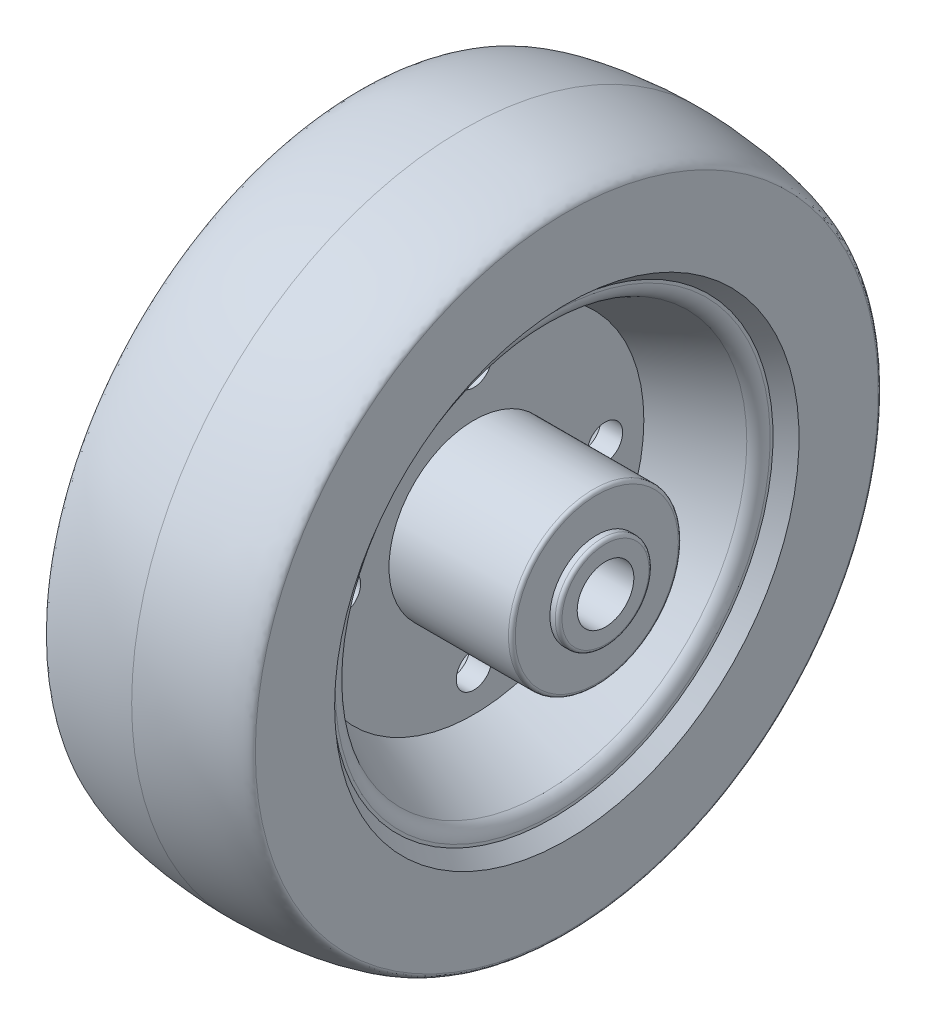
from build123d import *

# Parameters (mm, degrees)
SKETCH8_R            = 19.05
BOSS_EXTRUDE1_DEPTH  = 27.5463
SKETCH9_R            = 10.5156
BOSS_EXTRUDE2_DEPTH  = 1.9558
FILLET4_R            = 0.762
FILLET4_OF_MIRROR2_R = 0.762
SKETCH10_R           = 6.35
CUT_EXTRUDE5_DEPTH   = 64.9064
SKETCH11_R           = 3.96875
CUT_EXTRUDE6_DEPTH   = 35.4043


with BuildPart() as part:
    # Sketch5 → Revolve1 (revolve)
    with BuildSketch(Plane.XY):
        with BuildLine():
            Line((-23.2791, 0), (-23.2791, 69.85))
            add(Edge.make_bspline(
                [(-23.2791, 69.85), (-23.2791, 72.067965362), (-10.536247667, 74.295), (0, 74.295)],
                knots=[0, 0, 0, 0, 1, 1, 1, 1], degree=3))
            add(Edge.make_bspline(
                [(23.2791, 69.85), (23.2791, 72.067965362), (10.536247667, 74.295), (0, 74.295)],
                knots=[0, 0, 0, 0, 1, 1, 1, 1], degree=3))
            Line((23.2791, 69.85), (23.2791, 0))
            Line((23.2791, 0), (-23.2791, 0))
        make_face()
    revolve(axis=Axis((-23.2791, 0, 0), (1, 0, 0)))

    # Sketch7 → Cut-Revolve2 (revolve, cut)
    with BuildSketch(Plane(origin=(0, 0, 0), x_dir=(1, 0, 0), z_dir=(0, 1, 0))):
        with BuildLine():
            Line((2.4511, 0), (2.4511, 38.1))
            Line((2.4511, 38.1), (18.078907112, 45.553541634))
            ThreePointArc((18.078907112, 45.553541634), (19.555481427, 46.865602451), (20.1041, 48.763177998))
            Line((20.1041, 48.763177998), (20.1041, 49.412815204))
            Line((20.1041, 49.412815204), (23.2791, 52.07))
            Line((23.2791, 52.07), (23.2791, 0))
            Line((23.2791, 0), (2.4511, 0))
        make_face()
    cut_revolve2 = revolve(axis=Axis((-1000, 0, 0), (1, 0, 0)), mode=Mode.SUBTRACT)

    # Mirror1: Cut-Revolve2 across plane
    add(cut_revolve2.mirror(Plane(origin=(0, 0, 0), x_dir=(0, 0, 1), z_dir=(1, 0, 0))), mode=Mode.SUBTRACT)

    # Sketch8 → Boss-Extrude1 (add)
    with BuildSketch(Plane(origin=(2.4511, 0, 0), x_dir=(0, 0, -1), z_dir=(1, 0, 0))):
        Circle(SKETCH8_R)
    boss_extrude1 = extrude(amount=BOSS_EXTRUDE1_DEPTH)

    # Sketch9 → Boss-Extrude2 (add)
    with BuildSketch(Plane(origin=(29.9974, 0, 0), x_dir=(0, 0, -1), z_dir=(1, 0, 0))):
        Circle(SKETCH9_R)
    boss_extrude2 = extrude(amount=BOSS_EXTRUDE2_DEPTH)

    # Fillet4
    fillet4_edges = [part.edges().sort_by_distance(p)[0] for p in [
        (29.9974, 0, 19.05),
        (31.9532, 0, 10.5156),
    ]]
    fillet(fillet4_edges, radius=FILLET4_R)

    # Mirror2: Boss-Extrude1, Boss-Extrude2 across plane
    add(boss_extrude1.mirror(Plane(origin=(0, 0, 0), x_dir=(0, 0, 1), z_dir=(1, 0, 0))))
    add(boss_extrude2.mirror(Plane(origin=(0, 0, 0), x_dir=(0, 0, 1), z_dir=(1, 0, 0))))

    # Fillet4 of Mirror2
    fillet4_of_mirror2_edges = [part.edges().sort_by_distance(p)[0] for p in [
        (-29.9974, 0, 19.05),
        (-31.9532, 0, 10.5156),
    ]]
    fillet(fillet4_of_mirror2_edges, radius=FILLET4_OF_MIRROR2_R)

    # Sketch10 → Cut-Extrude5 (cut, through all)
    with BuildSketch(Plane.ZY.offset(31.9532)):
        Circle(SKETCH10_R)
    extrude(amount=-CUT_EXTRUDE5_DEPTH, mode=Mode.SUBTRACT)

    # Sketch11 → Cut-Extrude6 (cut, through all)
    with BuildSketch(Plane(origin=(2.4511, 0, 0), x_dir=(0, 0, -1), z_dir=(1, 0, 0))):
        with Locations((0, 29.36875)):
            Circle(SKETCH11_R)
        with Locations((29.36875, 0)):
            Circle(SKETCH11_R)
        with Locations((0, -29.36875)):
            Circle(SKETCH11_R)
        with Locations((-29.36875, 0)):
            Circle(SKETCH11_R)
    extrude(amount=-CUT_EXTRUDE6_DEPTH, mode=Mode.SUBTRACT)


solid = part.part
